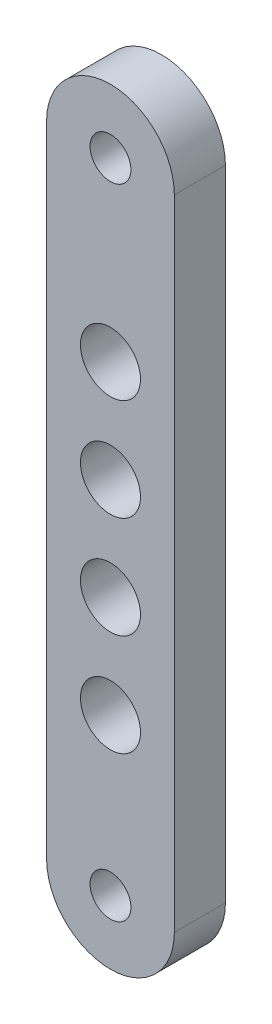
from build123d import *

# Parameters (mm, degrees)
SKETCH1_R           = 1.6
SKETCH1_R_2         = 2.35
BOSS_EXTRUDE1_DEPTH = 4


with BuildPart() as part:
    # Sketch1 → Boss-Extrude1 (new body)
    with BuildSketch(Plane.XY):
        with BuildLine():
            Line((-5, 0), (-5, 50))
            ThreePointArc((-5, 50), (0, 55), (5, 50))
            Line((5, 50), (5, 0))
            ThreePointArc((5, 0), (0, -5), (-5, 0))
        make_face()
        Circle(SKETCH1_R, mode=Mode.SUBTRACT)
        with Locations((0, 50)):
            Circle(SKETCH1_R, mode=Mode.SUBTRACT)
        with Locations((0, 36.17)):
            Circle(SKETCH1_R_2, mode=Mode.SUBTRACT)
        with Locations((0, 28.19)):
            Circle(SKETCH1_R_2, mode=Mode.SUBTRACT)
        with Locations((0, 20.21)):
            Circle(SKETCH1_R_2, mode=Mode.SUBTRACT)
        with Locations((0, 12.23)):
            Circle(SKETCH1_R_2, mode=Mode.SUBTRACT)
    extrude(amount=BOSS_EXTRUDE1_DEPTH)


solid = part.part
